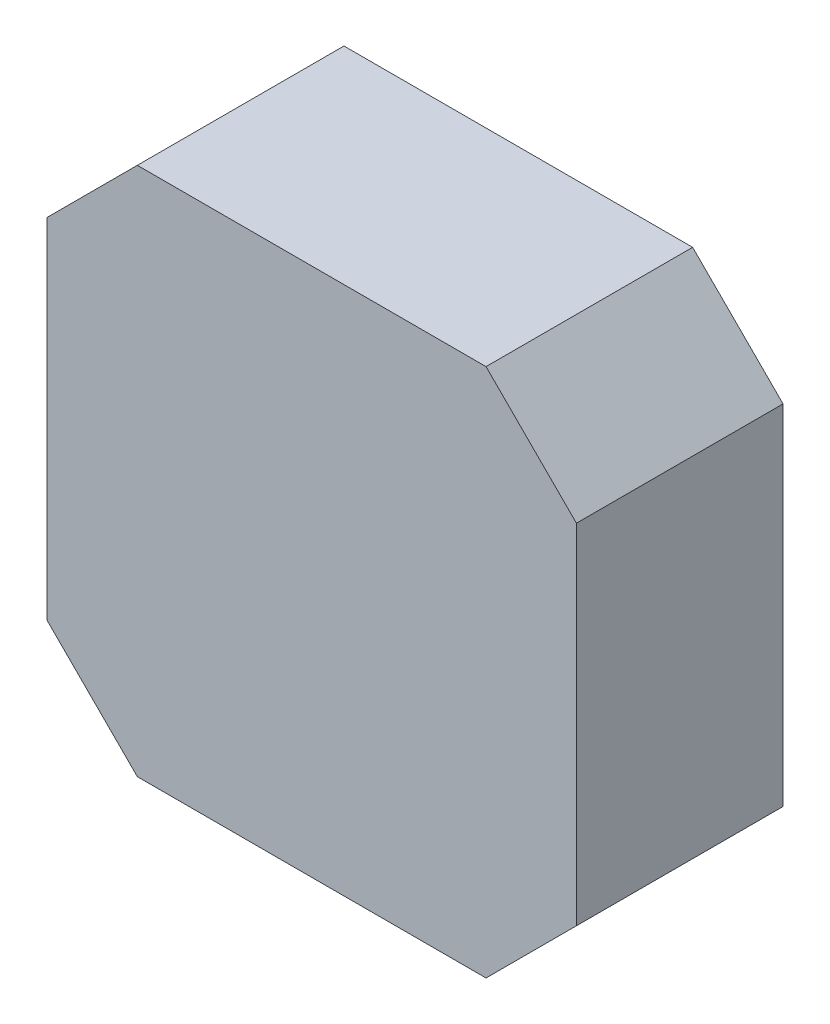
from build123d import *

# Parameters (mm, degrees)
SALIENTE_EXTRUIR1_DEPTH = 16


with BuildPart() as part:
    # Croquis1 → Saliente-Extruir1 (new body)
    with BuildSketch(Plane.XY):
        Polygon((-13.5, 20.5), (-20.5, 13.5), (-20.5, -13.5), (-13.5, -20.5), (13.5, -20.5), (20.5, -13.5), (20.5, 13.5), (13.5, 20.5), align=None)
    extrude(amount=SALIENTE_EXTRUIR1_DEPTH)


solid = part.part
